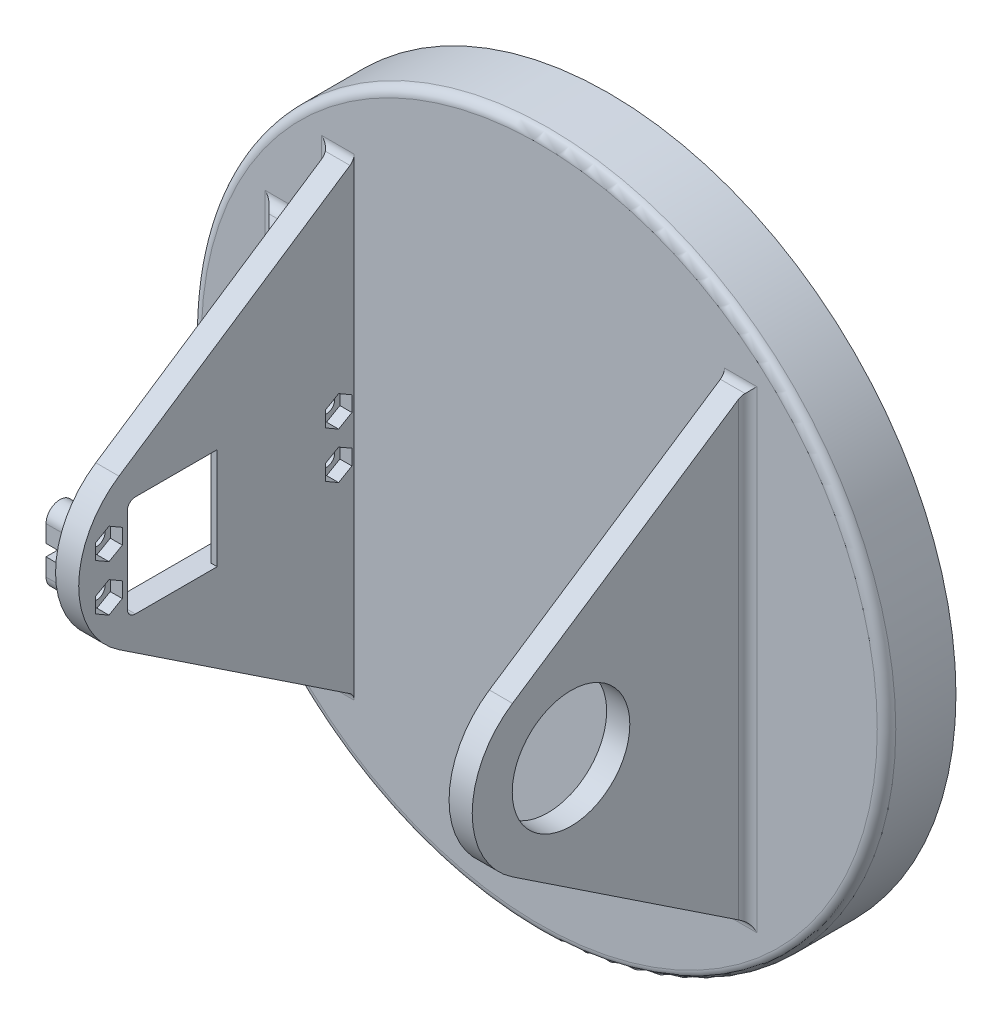
from build123d import *

# Parameters (mm, degrees)
SKETCH1_R           = 75
BASE_PLATE_DEPTH    = 15
SKETCH2_R           = 4.5
DRIVE_HOLES_DEPTH   = 10
CHAMFER1_SIZE       = 1
BASE_START          = 45
BASE_FIN_DEPTH      = 5
BASE_START_2        = 85
BASE_FIN_2_DEPTH    = 5
CUT_EXTRUDE1_REACH  = 122
CUT_EXTRUDE2_REACH  = 122
SKETCH7_R           = 1.75
BOSS_EXTRUDE1_DEPTH = 5.6
SKETCH9_R           = 1.75
CUT_EXTRUDE3_DEPTH  = 5.6
SKETCH10_W          = 4.6
SKETCH10_H          = 2.5
SKETCH10_W_2        = 6
CUT_EXTRUDE4_DEPTH  = 5.6
CUT_EXTRUDE5_DEPTH  = 2.6
BOSS_EXTRUDE2_DEPTH = 1.38
FILLET1_R           = 2
FILLET2_R           = 2
CUT_EXTRUDE6_REACH  = 37
SKETCH13_R          = 12.7
BOSS_EXTRUDE4_START = 20
BOSS_EXTRUDE4_DEPTH = 2.5
BOSS_EXTRUDE5_START = 20
BOSS_EXTRUDE5_DEPTH = 2.5
FILLET4_R           = 2


with BuildPart() as part:
    # Sketch1 → Base Plate (new body)
    with BuildSketch(Plane.XY):
        Circle(SKETCH1_R)
    extrude(amount=BASE_PLATE_DEPTH)

    # Sketch2 → Drive Holes (cut)
    with BuildSketch(Plane(origin=(0, 0, 0), x_dir=(-1, 0, 0), z_dir=(0, 0, -1))):
        with Locations((0, -25)):
            Circle(SKETCH2_R)
        with Locations((-23.776412907, -7.725424859)):
            Circle(SKETCH2_R)
        with Locations((-14.694631307, 20.225424859)):
            Circle(SKETCH2_R)
        with Locations((14.694631307, 20.225424859)):
            Circle(SKETCH2_R)
        with Locations((23.776412907, -7.725424859)):
            Circle(SKETCH2_R)
    extrude(amount=-DRIVE_HOLES_DEPTH, mode=Mode.SUBTRACT)

    # Chamfer1
    chamfer1_edges = [part.edges().sort_by_distance(p)[0] for p in [
        (28.276412907, -7.725424859, 0),
        (19.194631307, 20.225424859, 0),
        (-10.194631307, 20.225424859, 0),
        (-19.276412907, -7.725424859, 0),
        (4.5, -25, 0),
    ]]
    chamfer(chamfer1_edges, length=CHAMFER1_SIZE)

    # Sketch4 → Base Fin (add)
    with BuildSketch(Plane(origin=(0, 0, 0), x_dir=(0, 0, -1), z_dir=(1, 0, 0)).offset(BASE_START)):
        with BuildLine():
            Line((-15, 50), (-65.791986374, 16.233382914))
            ThreePointArc((-65.791986374, 16.233382914), (-74.493324261, 0), (-65.791986374, -16.233382914))
            Line((-65.791986374, -16.233382914), (-15, -50))
            Line((-15, -50), (-15, 50))
        make_face()
    extrude(amount=-BASE_FIN_DEPTH)

    # Sketch5 → Base Fin 2 (add)
    with BuildSketch(Plane.ZY.offset(-40).offset(BASE_START_2)):
        with BuildLine():
            Line((15, 50), (15, -50))
            Line((15, -50), (65.791986374, -16.233382914))
            ThreePointArc((65.791986374, -16.233382914), (74.493324261, 0), (65.791986374, 16.233382914))
            Line((65.791986374, 16.233382914), (15, 50))
        make_face()
    extrude(amount=-BASE_FIN_2_DEPTH)

    # Sketch6 → Cut-Extrude1 (cut, up to next)
    with BuildSketch(Plane.ZY.offset(45), mode=Mode.PRIVATE) as cut_extrude1_sk1:
        with BuildLine():
            Line((64, 8.832406236), (64, -9.567593764))
            ThreePointArc((64, -9.567593764), (63.487436867, -10.805030631), (62.25, -11.317593764))
            Line((62.25, -11.317593764), (24.05, -11.317593764))
            ThreePointArc((24.05, -11.317593764), (22.812563133, -10.805030631), (22.3, -9.567593764))
            Line((22.3, -9.567593764), (22.3, 8.832406236))
            ThreePointArc((22.3, 8.832406236), (22.812563133, 10.069843103), (24.05, 10.582406236))
            Line((24.05, 10.582406236), (62.25, 10.582406236))
            ThreePointArc((62.25, 10.582406236), (63.487436867, 10.069843103), (64, 8.832406236))
        make_face()
    cut_extrude1_tool1 = extrude(cut_extrude1_sk1.sketch, amount=-CUT_EXTRUDE1_REACH, mode=Mode.PRIVATE) & part.part
    add(cut_extrude1_tool1.solids().sort_by_distance((-45, -0.367594, 43.15))[0], mode=Mode.SUBTRACT)

    # Sketch7 → Cut-Extrude2 (cut, up to next)
    with BuildSketch(Plane.ZY.offset(45), mode=Mode.PRIVATE) as cut_extrude2_sk1:
        with Locations((18.35, 4.632406236)):
            Circle(SKETCH7_R)
    cut_extrude2_tool1 = extrude(cut_extrude2_sk1.sketch, amount=-CUT_EXTRUDE2_REACH, mode=Mode.PRIVATE) & part.part
    add(cut_extrude2_tool1.solids().sort_by_distance((-45, 4.632406, 18.35))[0], mode=Mode.SUBTRACT)
    # Sketch7 → Cut-Extrude2 (cut, up to next)
    with BuildSketch(Plane.ZY.offset(45), mode=Mode.PRIVATE) as cut_extrude2_sk2:
        with Locations((18.35, -5.367593764)):
            Circle(SKETCH7_R)
    cut_extrude2_tool2 = extrude(cut_extrude2_sk2.sketch, amount=-CUT_EXTRUDE2_REACH, mode=Mode.PRIVATE) & part.part
    add(cut_extrude2_tool2.solids().sort_by_distance((-45, -5.367594, 18.35))[0], mode=Mode.SUBTRACT)
    # Sketch7 → Cut-Extrude2 (cut, up to next)
    with BuildSketch(Plane.ZY.offset(45), mode=Mode.PRIVATE) as cut_extrude2_sk3:
        with Locations((67.95, -5.367593764)):
            Circle(SKETCH7_R)
    cut_extrude2_tool3 = extrude(cut_extrude2_sk3.sketch, amount=-CUT_EXTRUDE2_REACH, mode=Mode.PRIVATE) & part.part
    add(cut_extrude2_tool3.solids().sort_by_distance((-45, -5.367594, 67.95))[0], mode=Mode.SUBTRACT)
    # Sketch7 → Cut-Extrude2 (cut, up to next)
    with BuildSketch(Plane.ZY.offset(45), mode=Mode.PRIVATE) as cut_extrude2_sk4:
        with Locations((67.95, 4.632406236)):
            Circle(SKETCH7_R)
    cut_extrude2_tool4 = extrude(cut_extrude2_sk4.sketch, amount=-CUT_EXTRUDE2_REACH, mode=Mode.PRIVATE) & part.part
    add(cut_extrude2_tool4.solids().sort_by_distance((-45, 4.632406, 67.95))[0], mode=Mode.SUBTRACT)

    # Sketch8 → Boss-Extrude1 (add)
    with BuildSketch(Plane.ZY.offset(45)):
        with BuildLine():
            Line((70.95, 4.632406236), (70.95, -5.367593764))
            ThreePointArc((70.95, -5.367593764), (67.95, -8.367593764), (64.95, -5.367593764))
            Line((64.95, -5.367593764), (64.95, 4.632406236))
            ThreePointArc((64.95, 4.632406236), (67.95, 7.632406236), (70.95, 4.632406236))
        make_face()
        with BuildLine():
            Line((15, 7.632406236), (15, 0))
            Line((15, 0), (15, -8.367593764))
            Line((15, -8.367593764), (18.35, -8.367593764))
            ThreePointArc((18.35, -8.367593764), (20.471320344, -7.488914107), (21.35, -5.367593764))
            Line((21.35, -5.367593764), (21.35, 4.632406236))
            ThreePointArc((21.35, 4.632406236), (20.471320344, 6.75372658), (18.35, 7.632406236))
            Line((18.35, 7.632406236), (15, 7.632406236))
        make_face()
    extrude(amount=BOSS_EXTRUDE1_DEPTH)

    # Sketch9 → Cut-Extrude3 (cut)
    with BuildSketch(Plane(origin=(-45, 0, 0), x_dir=(0, 0, -1), z_dir=(1, 0, 0))):
        with Locations((-67.95, -5.367593764)):
            Circle(SKETCH9_R)
        with Locations((-67.95, 4.632406236)):
            Circle(SKETCH9_R)
        with Locations((-18.35, -5.367593764)):
            Circle(SKETCH9_R)
        with Locations((-18.35, 4.632406236)):
            Circle(SKETCH9_R)
    extrude(amount=-CUT_EXTRUDE3_DEPTH, mode=Mode.SUBTRACT)

    # Sketch10 → Cut-Extrude4 (cut)
    with BuildSketch(Plane.ZY.offset(50.6)):
        with Locations((19.05, -0.367593764)):
            Rectangle(SKETCH10_W, SKETCH10_H)
        with Locations((67.95, -0.324654002)):
            Rectangle(SKETCH10_W_2, SKETCH10_H)
    extrude(amount=-CUT_EXTRUDE4_DEPTH, mode=Mode.SUBTRACT)

    # Sketch11 → Cut-Extrude5 (cut)
    with BuildSketch(Plane(origin=(-40, 0, 0), x_dir=(0, 0, -1), z_dir=(1, 0, 0))):
        Polygon((-65.075, -7.027475788), (-65.075, -3.70771174), (-67.95, -2.047829716), (-70.825, -3.70771174), (-70.825, -7.027475788), (-67.95, -8.687357811), align=None)
        Polygon((-65.075, 2.972524212), (-65.075, 6.29228826), (-67.95, 7.952170284), (-70.825, 6.29228826), (-70.825, 2.972524212), (-67.95, 1.312642189), align=None)
        Polygon((-15.475, -7.027475788), (-15.475, -3.70771174), (-18.35, -2.047829716), (-21.225, -3.70771174), (-21.225, -7.027475788), (-18.35, -8.687357811), align=None)
        Polygon((-15.475, 2.972524212), (-15.475, 6.29228826), (-18.35, 7.952170284), (-21.225, 6.29228826), (-21.225, 2.972524212), (-18.35, 1.312642189), align=None)
    extrude(amount=-CUT_EXTRUDE5_DEPTH, mode=Mode.SUBTRACT)

    # Sketch12 → Boss-Extrude2 (add)
    with BuildSketch(Plane(origin=(-40, 0, 0), x_dir=(0, 0, -1), z_dir=(1, 0, 0))):
        with BuildLine():
            Line((-44.572101834, -11.317593764), (-44.572101834, 10.582406236))
            Line((-44.572101834, 10.582406236), (-24.05, 10.582406236))
            ThreePointArc((-24.05, 10.582406236), (-22.812563133, 10.069843104), (-22.3, 8.832406236))
            Line((-22.3, 8.832406236), (-22.3, -9.567593764))
            ThreePointArc((-22.3, -9.567593764), (-22.812563133, -10.805030631), (-24.05, -11.317593764))
            Line((-24.05, -11.317593764), (-44.572101834, -11.317593764))
        make_face()
    extrude(amount=-BOSS_EXTRUDE2_DEPTH)

    # Fillet1
    fillet1_edges = [part.edges().sort_by_distance(p)[0] for p in [
        (-45, -29.183796882, 15),
        (-47.8, -8.367593764, 15),
        (-47.8, 7.632406236, 15),
        (42.5, 50, 15),
        (42.5, -50, 15),
        (45, 0, 15),
        (-42.5, 50, 15),
        (-42.5, -50, 15),
        (-45, 28.816203118, 15),
    ]]
    fillet(fillet1_edges, radius=FILLET1_R)

    # Fillet2
    fillet2_edges = [part.edges().sort_by_distance(p)[0] for p in [
        (-75, 0, 15),
    ]]
    fillet(fillet2_edges, radius=FILLET2_R)

    # Sketch13 → Cut-Extrude6 (cut, up to next)
    with BuildSketch(Plane.ZY.offset(-40), mode=Mode.PRIVATE) as cut_extrude6_sk1:
        with Locations((53.15, -0.367593764)):
            Circle(SKETCH13_R)
    cut_extrude6_tool1 = extrude(cut_extrude6_sk1.sketch, amount=-CUT_EXTRUDE6_REACH, mode=Mode.PRIVATE) & part.part
    add(cut_extrude6_tool1.solids().sort_by_distance((40, -0.367594, 53.15))[0], mode=Mode.SUBTRACT)

    # Sketch17 → Boss-Extrude4 (add, symmetric)
    with BuildSketch(Plane(origin=(0, 0, 0), x_dir=(1, 0, 0), z_dir=(0, 1, 0)).offset(BOSS_EXTRUDE4_START)):
        Polygon((-42.667233731, -13), (-42.667233731, -30.724225819), (-60.39145955, -13), align=None)
    extrude(amount=BOSS_EXTRUDE4_DEPTH, both=True)

    # Sketch18 → Boss-Extrude5 (add, symmetric)
    with BuildSketch(Plane(origin=(-60.248558799, 10.197029926, -5.539416888), x_dir=(-1, 0, 0), z_dir=(0, 1, 0)).offset(BOSS_EXTRUDE5_START)):
        Polygon((-1.857099249, 20.539416888), (-15.248558799, 33.930876438), (-15.248558799, 20.539416888), align=None)
    extrude(amount=BOSS_EXTRUDE5_DEPTH, both=True)

    # Fillet4
    fillet4_edges = [part.edges().sort_by_distance(p)[0] for p in [
        (-45.585786438, 17.5, 15.585786438),
        (-45.585786438, 22.5, 15.585786438),
        (-45, 20, 28.39145955),
        (-58.39145955, 20, 15),
        (-52.695729775, 22.5, 15),
        (-45, 22.5, 22.695729775),
        (-52.695729775, 17.5, 15),
        (-45, 17.5, 22.695729775),
        (-45.585786438, 27.697029926, 15.585786438),
        (-45.585786438, 32.697029926, 15.585786438),
        (-52.695729775, 27.697029926, 15),
        (-45, 32.697029926, 22.695729775),
        (-52.695729775, 32.697029926, 15),
        (-58.39145955, 30.197029926, 15),
        (-45, 30.197029926, 28.39145955),
        (-45, 27.697029926, 22.695729775),
    ]]
    fillet(fillet4_edges, radius=FILLET4_R)


solid = part.part
